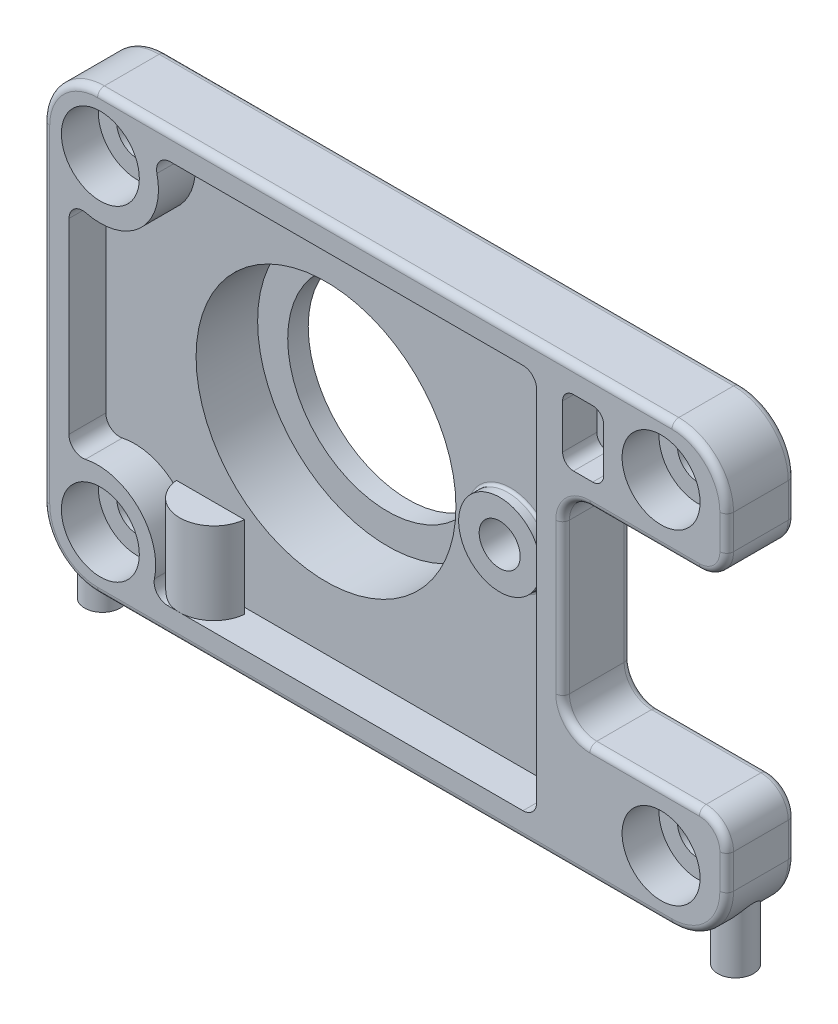
from build123d import *
from build123d.topology import SkipClean

# Parameters (mm, degrees)
SKETCH_1_R             = 1.5
SKETCH_1_R_2           = 9.5
EXTRUDE_1_DEPTH        = 5
CUT_EXTRUDE_START      = -2.7
SKETCH_2_R             = 2.85
SKETCH_2_R_2           = 1.5
CUT_EXTRUDE_1_DEPTH    = 2.7
FILLET_1_R             = 1
FILLET_2_R             = 4
FILLET_3_R             = 2
EXTRUDE_START          = 2.2
SKETCH_3_R             = 11.75
SKETCH_3_R_2           = 9.5
EXTRUDE_2_DEPTH        = 2.2
EXTRUDE_START_2        = 1.5
SKETCH_4_R             = 11.75
SKETCH_4_R_2           = 7.3
EXTRUDE_3_DEPTH        = 1.5
FILLET_4_R             = 0.5
FILLET_5_R             = 0.5
EXTRUDE_5_REACH        = 62.953
EXTRUDE_5_END_RADIUS   = 4
SKETCH_5_R             = 1.3
EXTRUDE_6_DEPTH        = 6
HOLE_WIZARD_M3_2_D     = 2.5
HOLE_WIZARD_M3_2_DEPTH = 6
HOLE_WIZARD_M3_2_TIP   = 0.751075774
FILLET_6_R             = 0.5
SKETCH_15_W            = 3
SKETCH_15_H            = 4.838747272
CUT_EXTRUDE_2_DEPTH    = 2.5
FILLET_7_R             = 0.8
SKETCH_16_R            = 3
SKETCH_16_R_2          = 1.5
EXTRUDE_9_DEPTH        = 0.8
EXTRUDE_START_3        = -4
SKETCH_16_2_R          = 3
EXTRUDE_10_DEPTH       = 4
CUT_EXTRUDE_START_2    = -3.6
SKETCH_16_3_R          = 1.5
CUT_EXTRUDE_3_DEPTH    = 3.6
FILLET_8_R             = 0.2
SKETCH_17_R            = 2.85
SKETCH_17_R_2          = 1.5
CUT_EXTRUDE_4_DEPTH    = 1


with BuildPart() as part:
    # 草图1 → 凸台-拉伸1 (new body)
    with BuildSketch(Plane.XY):
        Polygon((0, 0), (50, 0), (50, 8.5), (38, 8.5), (38, 23.5), (50, 23.5), (50, 32), (0, 32), align=None)
        with Locations((4.2, 27.9)):
            Circle(SKETCH_1_R, mode=Mode.SUBTRACT)
        with Locations((45.2, 27.9)):
            Circle(SKETCH_1_R, mode=Mode.SUBTRACT)
        with Locations((45.2, 4.1)):
            Circle(SKETCH_1_R, mode=Mode.SUBTRACT)
        with Locations((4.2, 4.1)):
            Circle(SKETCH_1_R, mode=Mode.SUBTRACT)
        with Locations((18, 16)):
            Circle(SKETCH_1_R_2, mode=Mode.SUBTRACT)
    extrude(amount=EXTRUDE_1_DEPTH)

    # 草图2 → 切除-拉伸1 (cut)
    # profile 1 of 5: a face of its own
    with BuildSketch(Plane.XY.offset(5).offset(CUT_EXTRUDE_START)):
        with BuildLine():
            Line((7.694928957, 1.9), (36.1, 1.9))
            Line((36.1, 1.9), (36.1, 30.1))
            Line((36.1, 30.1), (7.836275567, 30.1))
            ThreePointArc((7.836275567, 30.1), (7.168529783, 24.858564332), (1.912438276, 24.318162293))
            Line((1.912438276, 24.318162293), (1.9, 7.694928957))
            ThreePointArc((1.9, 7.694928957), (7.00520382, 7.00520382), (7.694928957, 1.9))
        make_face()
    # profile 2 of 5: a face of its own
    with BuildSketch(Plane.XY.offset(5).offset(CUT_EXTRUDE_START)):
        with Locations((4.2, 27.9)):
            Circle(SKETCH_2_R)
        with Locations((4.2, 27.9)):
            Circle(SKETCH_2_R_2, mode=Mode.SUBTRACT)
    # profile 3 of 5: a face of its own
    with BuildSketch(Plane.XY.offset(5).offset(CUT_EXTRUDE_START)):
        with Locations((4.2, 4.1)):
            Circle(SKETCH_2_R)
        with Locations((4.2, 4.1)):
            Circle(SKETCH_2_R_2, mode=Mode.SUBTRACT)
    # profile 4 of 5: a face of its own
    with BuildSketch(Plane.XY.offset(5).offset(CUT_EXTRUDE_START)):
        with Locations((45.2, 4.1)):
            Circle(SKETCH_2_R)
        with Locations((45.2, 4.1)):
            Circle(SKETCH_2_R_2, mode=Mode.SUBTRACT)
    # profile 5 of 5: a face of its own
    with BuildSketch(Plane.XY.offset(5).offset(CUT_EXTRUDE_START)):
        with Locations((45.2, 27.9)):
            Circle(SKETCH_2_R)
        with Locations((45.2, 27.9)):
            Circle(SKETCH_2_R_2, mode=Mode.SUBTRACT)
    extrude(amount=CUT_EXTRUDE_1_DEPTH, mode=Mode.SUBTRACT)

    # 圆角1
    fillet_1_edges = [part.edges().sort_by_distance(p)[0] for p in [
        (36.1, 1.9, 3.65),
        (7.836275567, 30.1, 3.65),
        (1.912438276, 24.318162293, 3.65),
        (1.9, 7.694928957, 3.65),
        (7.694928957, 1.9, 3.65),
        (36.1, 30.1, 3.65),
    ]]
    fillet(fillet_1_edges, radius=FILLET_1_R)

    # 圆角2
    fillet_2_edges = [part.edges().sort_by_distance(p)[0] for p in [
        (0, 0, 2.5),
        (0, 32, 2.5),
        (50, 0, 2.5),
        (50, 32, 2.5),
    ]]
    fillet(fillet_2_edges, radius=FILLET_2_R)

    # 圆角3
    fillet_3_edges = [part.edges().sort_by_distance(p)[0] for p in [
        (38, 23.5, 2.5),
        (38, 8.5, 2.5),
        (50, 8.5, 2.5),
        (50, 23.5, 2.5),
    ]]
    fillet(fillet_3_edges, radius=FILLET_3_R)

    # 草图3 → 凸台-拉伸2 (add)
    with SkipClean():  # the faces are left unmerged after this step: merging them gives an invalid solid
        with BuildSketch(Plane(origin=(0, 0, 0), x_dir=(-1, 0, 0), z_dir=(0, 0, -1)).offset(EXTRUDE_START)):
            with Locations((-18, 16)):
                Circle(SKETCH_3_R)
            with Locations((-18, 16)):
                Circle(SKETCH_3_R_2, mode=Mode.SUBTRACT)
        extrude(amount=-EXTRUDE_2_DEPTH)

    # 草图4 → 凸台-拉伸3 (add)
    with SkipClean():  # the faces are left unmerged after this step: merging them gives an invalid solid
        with BuildSketch(Plane(origin=(0, 0, -2.2), x_dir=(-1, 0, 0), z_dir=(0, 0, -1)).offset(EXTRUDE_START_2)):
            with Locations((-18, 16)):
                Circle(SKETCH_4_R)
            with Locations((-18, 16)):
                Circle(SKETCH_4_R_2, mode=Mode.SUBTRACT)
        extrude(amount=-EXTRUDE_3_DEPTH)

    # 圆角4
    fillet_4_edges = [part.edges().sort_by_distance(p)[0] for p in [
        (29.75, 16, -3.7),
    ]]
    fillet(fillet_4_edges, radius=FILLET_4_R)

    # 圆角5
    fillet_5_edges = [part.edges().sort_by_distance(p)[0] for p in [
        (38.585786438, 22.914213562, 0),
        (38, 16, 0),
        (38.585786438, 9.085786438, 0),
        (44, 8.5, 0),
        (49.414213562, 7.914213562, 0),
        (50, 5.25, 0),
        (48.828427125, 1.171572875, 0),
        (25, 0, 0),
        (1.171572875, 1.171572875, 0),
        (0, 16, 0),
        (1.171572875, 30.828427125, 0),
        (25, 32, 0),
        (48.828427125, 30.828427125, 0),
        (50, 26.75, 0),
        (49.414213562, 24.085786438, 0),
        (44, 23.5, 0),
    ]]
    fillet(fillet_5_edges, radius=FILLET_5_R)

    # 凸台-拉伸5: up to this cylinder (the profile starts outside it)
    extrude_5_end = Plane(origin=(46, 4, 2.5), z_dir=(0, 0, -1)) * Cylinder(EXTRUDE_5_END_RADIUS, 134.906, mode=Mode.PRIVATE)
    # 草图5 → 凸台-拉伸5 (add, up to the surface)
    with BuildSketch(Plane(origin=(0, -2.5, 0), x_dir=(-1, 0, 0), z_dir=(0, -1, 0)), mode=Mode.PRIVATE) as extrude_5_sk1:
        with Locations((-48.15, -2.5)):
            Circle(SKETCH_5_R)
    extrude_5_tool1 = extrude(extrude_5_sk1.sketch, amount=-EXTRUDE_5_REACH, mode=Mode.PRIVATE) - extrude_5_end
    extrude_5 = extrude_5_tool1.solids().sort_by_distance((48.15, -2.5, 2.5))[0]
    add(extrude_5)

    # 镜向3: 凸台-拉伸5 across plane
    add(extrude_5.mirror(Plane(origin=(25, 0, 0), x_dir=(0, 0, 1), z_dir=(1, 0, 0))))

    # 草图8 → 凸台-拉伸6 (add)
    with BuildSketch(Plane(origin=(0, 1.9, 0), x_dir=(1, 0, 0), z_dir=(0, 1, 0))):
        with BuildLine():
            Line((7.512531407, -2.75), (12.487468593, -2.75))
            ThreePointArc((12.487468593, -2.75), (10, -5), (7.512531407, -2.75))
        make_face()
    extrude(amount=EXTRUDE_6_DEPTH)

    # M3 螺纹孔2
    with Locations(Plane(origin=(0, 0, 0), x_dir=(-1, 0, 0), z_dir=(0, -1, 0))):
        with Locations((-9.85, -2.5), (-40.15, -2.5)):
            Hole(HOLE_WIZARD_M3_2_D / 2, depth=HOLE_WIZARD_M3_2_DEPTH)
            with Locations((0, 0, -(HOLE_WIZARD_M3_2_DEPTH + HOLE_WIZARD_M3_2_TIP / 2))):  # 118° drill point
                Cone(0, HOLE_WIZARD_M3_2_D / 2, HOLE_WIZARD_M3_2_TIP, mode=Mode.SUBTRACT)

    # 圆角6
    fillet_6_edges = [part.edges().sort_by_distance(p)[0] for p in [
        (1.171572875, 1.171572875, 5),
        (0, 16, 5),
        (1.171572875, 30.828427125, 5),
        (25, 32, 5),
        (48.828427125, 30.828427125, 5),
        (50, 26.75, 5),
        (49.414213562, 24.085786438, 5),
        (44, 23.5, 5),
        (38.585786438, 22.914213562, 5),
        (38, 16, 5),
        (38.585786438, 9.085786438, 5),
        (44, 8.5, 5),
        (49.414213562, 7.914213562, 5),
        (50, 5.25, 5),
        (48.828427125, 1.171572875, 5),
        (25, 0, 5),
    ]]
    fillet(fillet_6_edges, radius=FILLET_6_R)

    # 草图15 → 切除-拉伸2 (cut)
    with BuildSketch(Plane.XY.offset(5)):
        with Locations((39.5, 27.680626364)):
            Rectangle(SKETCH_15_W, SKETCH_15_H)
    extrude(amount=-CUT_EXTRUDE_2_DEPTH, mode=Mode.SUBTRACT)

    # 圆角7
    fillet_7_edges = [part.edges().sort_by_distance(p)[0] for p in [
        (41, 30.1, 3.75),
        (38, 30.1, 3.75),
        (41, 25.261252728, 3.75),
        (38, 25.261252728, 3.75),
    ]]
    fillet(fillet_7_edges, radius=FILLET_7_R)

    # 草图16 → 凸台-拉伸9 (add)
    with BuildSketch(Plane.XY.offset(2.3)):
        with Locations((31.5, 16)):
            Circle(SKETCH_16_R)
        with Locations((31.5, 16)):
            Circle(SKETCH_16_R_2, mode=Mode.SUBTRACT)
    extrude(amount=EXTRUDE_9_DEPTH)

    # 草图16<2> → 凸台-拉伸10 (add)
    with BuildSketch(Plane.XY.offset(2.3).offset(EXTRUDE_START_3)):
        with Locations((31.5, 16)):
            Circle(SKETCH_16_2_R)
    extrude(amount=EXTRUDE_10_DEPTH)

    # 草图16<3> → 切除-拉伸3 (cut)
    with BuildSketch(Plane.XY.offset(2.3).offset(CUT_EXTRUDE_START_2)):
        with Locations((31.5, 16)):
            Circle(SKETCH_16_3_R)
    extrude(amount=CUT_EXTRUDE_3_DEPTH, mode=Mode.SUBTRACT)

    # 圆角8
    fillet_8_edges = [part.edges().sort_by_distance(p)[0] for p in [
        (28.5, 16, 2.3),
        (32.743036158, 13.269640846, -1.7),
    ]]
    fillet(fillet_8_edges, radius=FILLET_8_R)

    # 草图17 → 切除-拉伸4 (cut)
    # profile 1 of 4: a face of its own
    with BuildSketch(Plane(origin=(0, 0, 0), x_dir=(-1, 0, 0), z_dir=(0, 0, -1))):
        with Locations((-45.2, 27.9)):
            Circle(SKETCH_17_R)
        with Locations((-45.2, 27.9)):
            Circle(SKETCH_17_R_2, mode=Mode.SUBTRACT)
    # profile 2 of 4: a face of its own
    with BuildSketch(Plane(origin=(0, 0, 0), x_dir=(-1, 0, 0), z_dir=(0, 0, -1))):
        with Locations((-4.2, 27.9)):
            Circle(SKETCH_17_R)
        with Locations((-4.2, 27.9)):
            Circle(SKETCH_17_R_2, mode=Mode.SUBTRACT)
    # profile 3 of 4: a face of its own
    with BuildSketch(Plane(origin=(0, 0, 0), x_dir=(-1, 0, 0), z_dir=(0, 0, -1))):
        with Locations((-45.2, 4.1)):
            Circle(SKETCH_17_R)
        with Locations((-45.2, 4.1)):
            Circle(SKETCH_17_R_2, mode=Mode.SUBTRACT)
    # profile 4 of 4: a face of its own
    with BuildSketch(Plane(origin=(0, 0, 0), x_dir=(-1, 0, 0), z_dir=(0, 0, -1))):
        with Locations((-4.2, 4.1)):
            Circle(SKETCH_17_R)
        with Locations((-4.2, 4.1)):
            Circle(SKETCH_17_R_2, mode=Mode.SUBTRACT)
    extrude(amount=-CUT_EXTRUDE_4_DEPTH, mode=Mode.SUBTRACT)


solid = part.part
